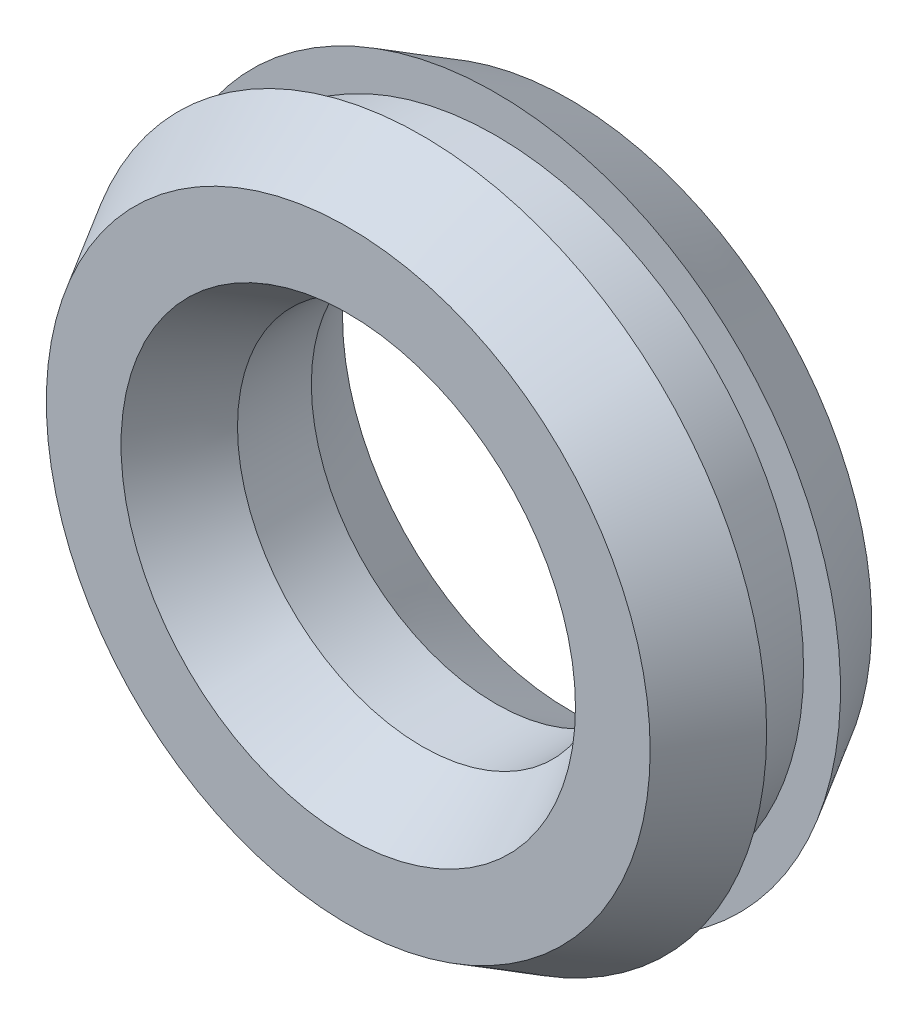
from build123d import *

# Parameters (mm, degrees)
SKETCH1_R           = 12.5
SKETCH1_R_2         = 7.5
BOSS_EXTRUDE1_DEPTH = 3
SKETCH2_R           = 14
SKETCH2_R_2         = 7.5
BOSS_EXTRUDE2_DEPTH = 3
BOSS_EXTRUDE2_TAPER = 30
SKETCH3_R           = 14
SKETCH3_R_2         = 7.5
BOSS_EXTRUDE3_DEPTH = 3
BOSS_EXTRUDE3_TAPER = 30


with BuildPart() as part:
    # Sketch1 → Boss-Extrude1 (new body)
    with BuildSketch(Plane.XY):
        Circle(SKETCH1_R)
        Circle(SKETCH1_R_2, mode=Mode.SUBTRACT)
    extrude(amount=BOSS_EXTRUDE1_DEPTH)

    # Sketch2 → Boss-Extrude2 (add)
    with BuildSketch(Plane.XY.offset(3)):
        Circle(SKETCH2_R)
        Circle(SKETCH2_R_2, mode=Mode.SUBTRACT)
    extrude(amount=BOSS_EXTRUDE2_DEPTH, taper=BOSS_EXTRUDE2_TAPER)

    # Sketch3 → Boss-Extrude3 (add)
    with BuildSketch(Plane(origin=(0, 0, 0), x_dir=(-1, 0, 0), z_dir=(0, 0, -1))):
        Circle(SKETCH3_R)
        Circle(SKETCH3_R_2, mode=Mode.SUBTRACT)
    extrude(amount=BOSS_EXTRUDE3_DEPTH, taper=BOSS_EXTRUDE3_TAPER)


solid = part.part
